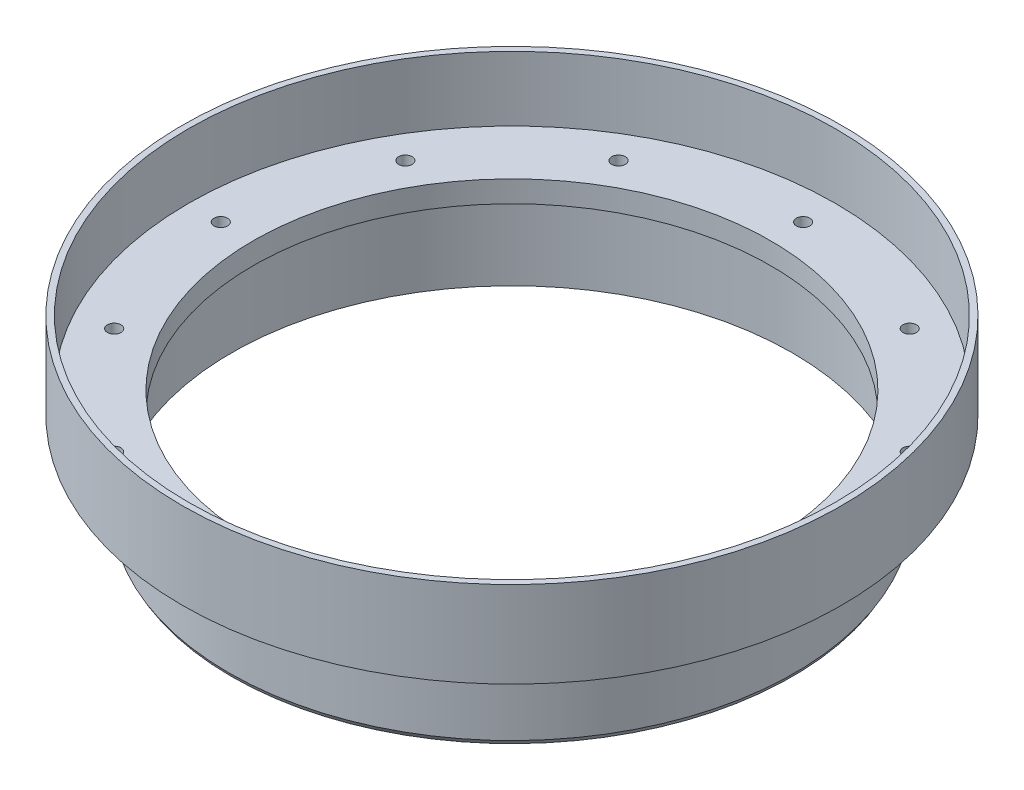
from build123d import *

# Parameters (mm, degrees)
SCREW_HOLES_COUNT = 12


with BuildPart() as part:
    # Cross Section → Main (revolve)
    with BuildSketch(Plane.XY):
        Polygon((-38.1, 0), (-38.1, -3.175), (-41.275, -3.175), (-41.275, -15.875), (-41.656, -15.215088642), (-41.656, -3.175), (-48.514, -3.175), (-48.514, 9.525), (-47.625, 9.525), (-47.625, 0), align=None)
    revolve(axis=Axis((0, 55, 0), (0, -1, 0)))

    # Sketch7 → #3-48 Tapped Hole1 (revolve, cut)
    with BuildSketch(Plane(origin=(-42.8625, 0, 0), x_dir=(0, 0, 1), z_dir=(1, 0, 0))):
        Polygon((0, 0), (0, 3.901027994), (0.99695, 3.302), (0.99695, 0), align=None)
    f_3_48_tapped_hole1 = revolve(axis=Axis((-42.8625, 6.35, 0), (0, -1, 0)), mode=Mode.SUBTRACT)

    # Screw Holes: #3-48 Tapped Hole1 ×12 about axis
    screw_holes_axis = Axis((0, 0, 0), (0, 1, 0))
    for i in range(1, SCREW_HOLES_COUNT):
        add(f_3_48_tapped_hole1.rotate(screw_holes_axis, i * 360 / SCREW_HOLES_COUNT), mode=Mode.SUBTRACT)


solid = part.part
